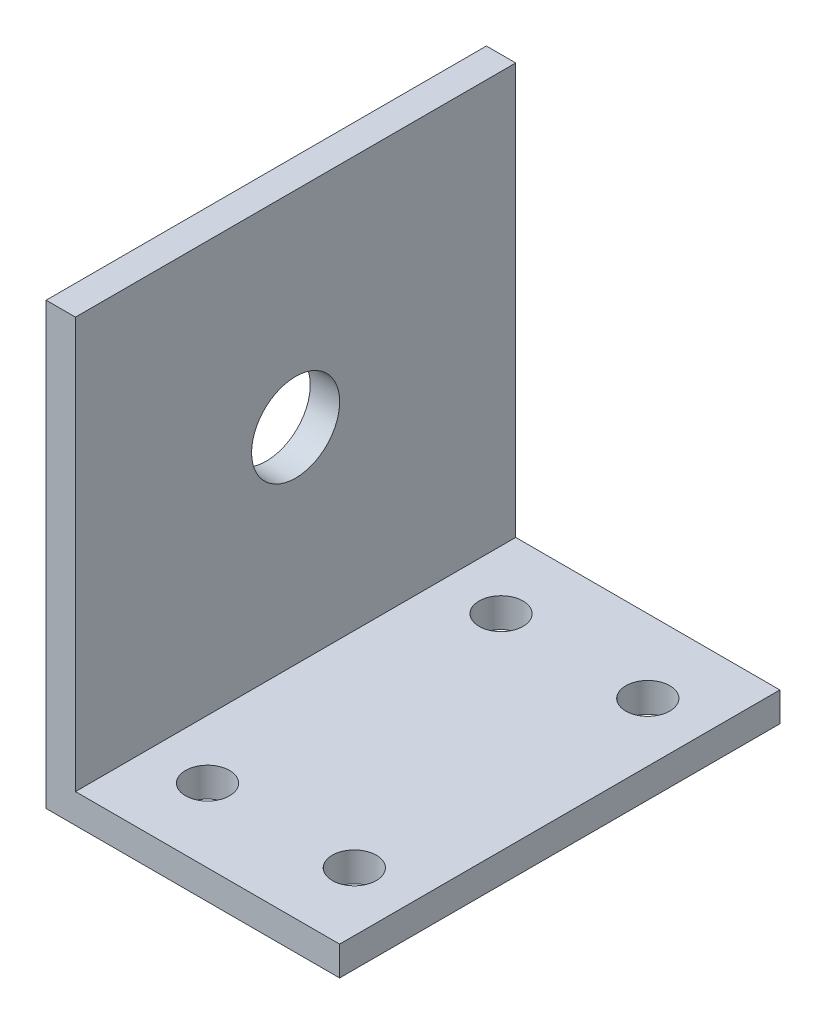
from build123d import *

# Parameters (mm, degrees)
EXTRUDE_1_DEPTH     = 20
SKETCH_2_R          = 3
CUT_EXTRUDE_1_DEPTH = 39
SKETCH_4_W          = 3
SKETCH_4_H          = 20
CUT_EXTRUDE_3_DEPTH = 8
SKETCH_5_W          = 35
SKETCH_5_H          = 20
CUT_EXTRUDE_4_DEPTH = 1
SKETCH_6_W          = 20
SKETCH_6_H          = 28
CUT_EXTRUDE_5_DEPTH = 1
SKETCH_8_W          = 20
SKETCH_8_H          = 2
CUT_EXTRUDE_6_DEPTH = 18
EXTRUDE_2_DEPTH     = 10
SKETCH_10_R         = 1.5
CUT_EXTRUDE_7_DEPTH = 10


with BuildPart() as part:
    # 草图1 → 凸台-拉伸1 (new body)
    with BuildSketch(Plane.XY):
        Polygon((0, 0), (0, 38), (3, 38), (3, 3), (38, 3), (38, 0), align=None)
    extrude(amount=EXTRUDE_1_DEPTH)

    # 草图2 → 切除-拉伸1 (cut, through all)
    with BuildSketch(Plane.ZY):
        with Locations((5, 16)):
            Circle(SKETCH_2_R)
    extrude(amount=-CUT_EXTRUDE_1_DEPTH, mode=Mode.SUBTRACT)

    # 草图4 → 切除-拉伸3 (cut)
    with BuildSketch(Plane(origin=(0, 38, 0), x_dir=(1, 0, 0), z_dir=(0, 1, 0))):
        with Locations((1.5, -10)):
            Rectangle(SKETCH_4_W, SKETCH_4_H)
    extrude(amount=-CUT_EXTRUDE_3_DEPTH, mode=Mode.SUBTRACT)

    # 草图5 → 切除-拉伸4 (cut)
    with BuildSketch(Plane(origin=(0, 3, 0), x_dir=(1, 0, 0), z_dir=(0, 1, 0))):
        with Locations((20.5, -10)):
            Rectangle(SKETCH_5_W, SKETCH_5_H)
    extrude(amount=-CUT_EXTRUDE_4_DEPTH, mode=Mode.SUBTRACT)

    # 草图6 → 切除-拉伸5 (cut)
    with BuildSketch(Plane(origin=(3, 0, 0), x_dir=(0, 0, -1), z_dir=(1, 0, 0))):
        with Locations((-10, 16)):
            Rectangle(SKETCH_6_W, SKETCH_6_H)
    extrude(amount=-CUT_EXTRUDE_5_DEPTH, mode=Mode.SUBTRACT)

    # 草图8 → 切除-拉伸6 (cut)
    with BuildSketch(Plane(origin=(38, 0, 0), x_dir=(0, 0, -1), z_dir=(1, 0, 0))):
        with Locations((-10, 1)):
            Rectangle(SKETCH_8_W, SKETCH_8_H)
    extrude(amount=-CUT_EXTRUDE_6_DEPTH, mode=Mode.SUBTRACT)

    # 草图9 → 凸台-拉伸2 (add)
    with BuildSketch(Plane(origin=(0, 0, 0), x_dir=(-1, 0, 0), z_dir=(0, 0, -1))):
        Polygon((0, 0), (0, 30), (-2, 30), (-2, 2), (-20, 2), (-20, 0), align=None)
    extrude(amount=EXTRUDE_2_DEPTH)

    # 草图10 → 切除-拉伸7 (cut)
    with BuildSketch(Plane(origin=(0, 2, 0), x_dir=(1, 0, 0), z_dir=(0, 1, 0))):
        with Locations((16, -15)):
            Circle(SKETCH_10_R)
        with Locations((16, 5)):
            Circle(SKETCH_10_R)
        with Locations((6, -15)):
            Circle(SKETCH_10_R)
        with Locations((6, 5)):
            Circle(SKETCH_10_R)
    extrude(amount=-CUT_EXTRUDE_7_DEPTH, mode=Mode.SUBTRACT)


solid = part.part
